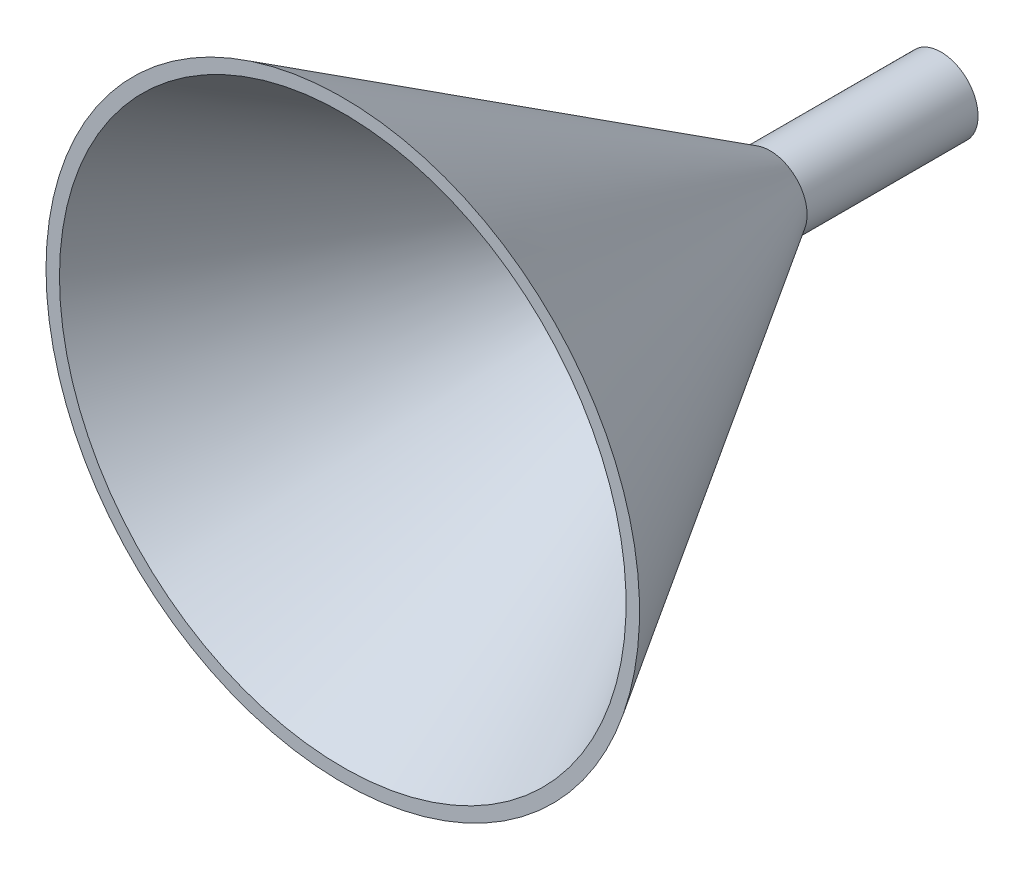
from build123d import *


with BuildPart() as part:
    # Sketch1 → Revolve1 (revolve)
    with BuildSketch(Plane(origin=(0, 0, 0), x_dir=(1, 0, 0), z_dir=(0, 1, 0))):
        Polygon((0, 0), (0, -25.4), (38.1, -88.9), (40.1, -88.9), (1.5, -25.4), (1.5, 0), align=None)
    revolve(axis=Axis((-4, 0, 0), (0, 0, 1)))


solid = part.part
